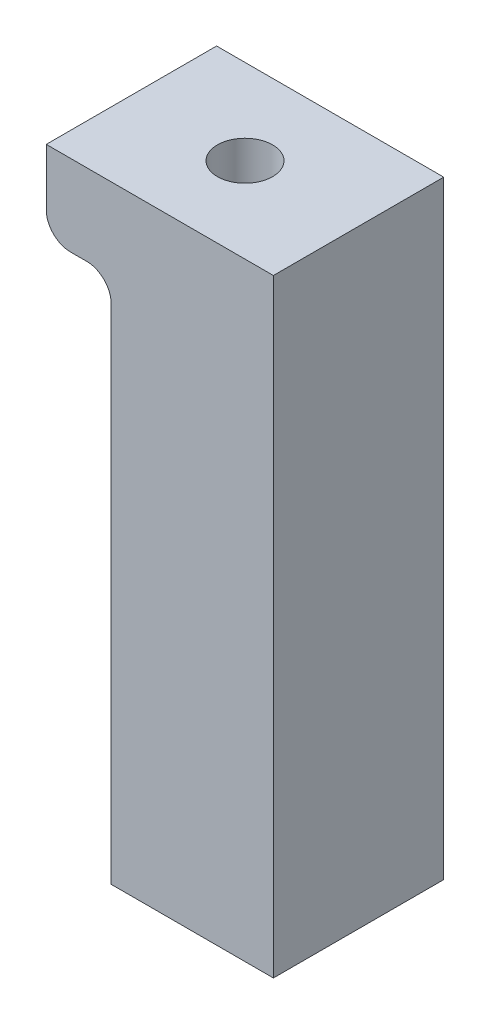
from build123d import *

# Parameters (mm, degrees)
SKETCH_1_W             = 28
SKETCH_1_H             = 21
EXTRUDE_1_DEPTH        = 75
SKETCH_6_W             = 8
SKETCH_6_H             = 65
CUT_EXTRUDE_1_DEPTH    = 22
FILLET_3_R             = 3
HOLE_WIZARD_M6_1_D     = 5
HOLE_WIZARD_M6_1_DEPTH = 19.75
HOLE_WIZARD_M6_1_TIP   = 1.502151548


with BuildPart() as part:
    # 草图1 → 凸台-拉伸1 (new body)
    with BuildSketch(Plane(origin=(0, 0, 0), x_dir=(1, 0, 0), z_dir=(0, 1, 0))):
        Rectangle(SKETCH_1_W, SKETCH_1_H)
    extrude(amount=EXTRUDE_1_DEPTH)

    # 草图5 → M8 螺纹孔1 (revolve, cut)
    with BuildSketch(Plane(origin=(0, 75, 0), x_dir=(0, 0, 1), z_dir=(1, 0, 0))):
        Polygon((0, 0), (0, 21.792926105), (3.4, 19.75), (3.4, 0), align=None)
    revolve(axis=Axis((0, 81.35, 0), (0, -1, 0)), mode=Mode.SUBTRACT)

    # 草图6 → 切除-拉伸1 (cut, through all)
    with BuildSketch(Plane.XY.offset(10.5)):
        with Locations((-10, 32.5)):
            Rectangle(SKETCH_6_W, SKETCH_6_H)
    extrude(amount=-CUT_EXTRUDE_1_DEPTH, mode=Mode.SUBTRACT)

    # 圆角3
    fillet_3_edges = [part.edges().sort_by_distance(p)[0] for p in [
        (-14, 65, 0),
        (-6, 65, 0),
    ]]
    fillet(fillet_3_edges, radius=FILLET_3_R)

    # M6 螺纹孔1
    with Locations(Plane(origin=(0, 0, 0), x_dir=(0, 0, -1), z_dir=(0, -1, 0))):
        with Locations((0, 0)):
            Hole(HOLE_WIZARD_M6_1_D / 2, depth=HOLE_WIZARD_M6_1_DEPTH)
            with Locations((0, 0, -(HOLE_WIZARD_M6_1_DEPTH + HOLE_WIZARD_M6_1_TIP / 2))):  # 118° drill point
                Cone(0, HOLE_WIZARD_M6_1_D / 2, HOLE_WIZARD_M6_1_TIP, mode=Mode.SUBTRACT)


solid = part.part
